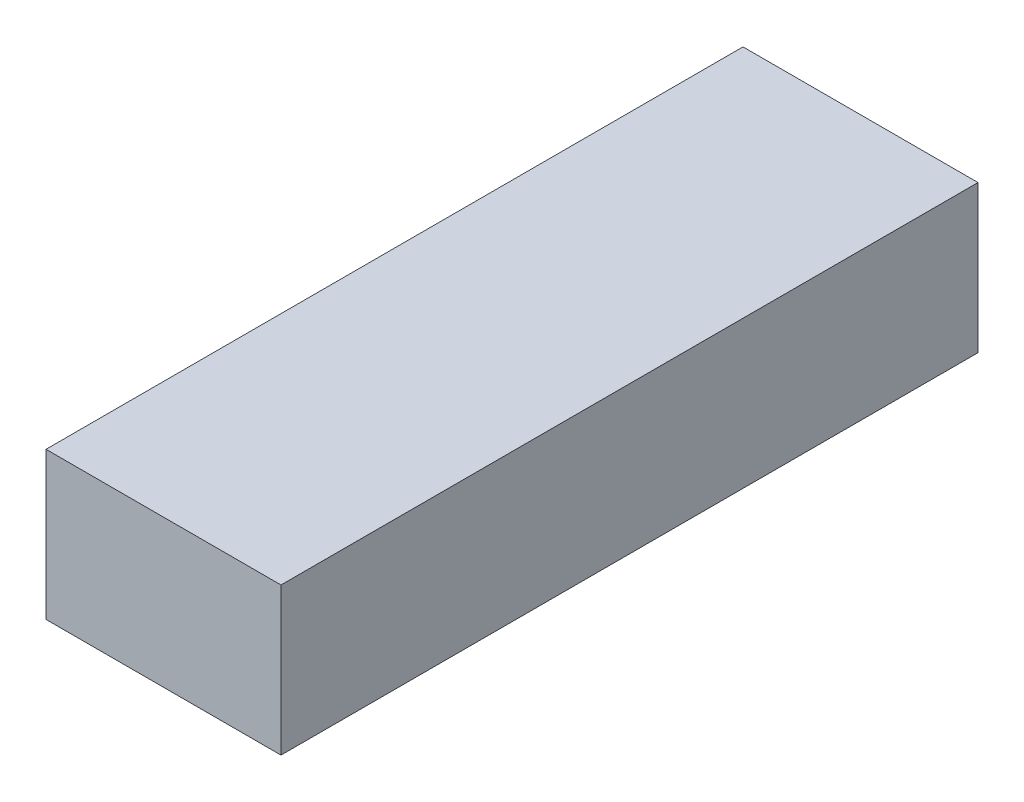
from build123d import *

# Parameters (mm, degrees)
SKETCH1_W           = 11.8
SKETCH1_H           = 35
SKETCH1_W_2         = 7.8
SKETCH1_H_2         = 7.8
BOSS_EXTRUDE1_DEPTH = 2.8
SKETCH2_W           = 11.8
SKETCH2_H           = 35
BOSS_EXTRUDE2_DEPTH = 3
SKETCH3_W           = 11.8
SKETCH3_H           = 35
BOSS_EXTRUDE3_DEPTH = 1.6
CUT_EXTRUDE1_REACH  = 15.365
SKETCH4_R           = 4.125


with BuildPart() as part:
    # Sketch1 → Boss-Extrude1 (new body)
    with BuildSketch(Plane(origin=(0, 0, 0), x_dir=(1, 0, 0), z_dir=(0, 1, 0))):
        with Locations((0, 9.2)):
            Rectangle(SKETCH1_W, SKETCH1_H)
        Rectangle(SKETCH1_W_2, SKETCH1_H_2, mode=Mode.SUBTRACT)
    extrude(amount=BOSS_EXTRUDE1_DEPTH)

    # Sketch2 → Boss-Extrude2 (add)
    with BuildSketch(Plane(origin=(0, 2.8, 0), x_dir=(1, 0, 0), z_dir=(0, 1, 0))):
        with Locations((0, 9.2)):
            Rectangle(SKETCH2_W, SKETCH2_H)
        Polygon((-3.9, 3.9), (-3.4, 3.9), (-3.4, 24.7), (3.4, 24.7), (3.4, 3.9), (3.9, 3.9), (3.9, -3.9), (-3.9, -3.9), align=None, mode=Mode.SUBTRACT)
        Polygon((3.4, -3.4), (-3.4, -3.4), (-3.4, 3.4), (-3.4, 3.9), (-3.9, 3.9), (-3.9, -3.9), (3.9, -3.9), (3.9, 3.9), (3.4, 3.9), (3.4, 3.4), align=None)
    extrude(amount=BOSS_EXTRUDE2_DEPTH)

    # Sketch3 → Boss-Extrude3 (add)
    with BuildSketch(Plane(origin=(0, 5.8, 0), x_dir=(1, 0, 0), z_dir=(0, 1, 0))):
        with Locations((0, 9.2)):
            Rectangle(SKETCH3_W, SKETCH3_H)
    extrude(amount=BOSS_EXTRUDE3_DEPTH)

    # Cut-Extrude1: up to this face of the body (flat: up to its plane)
    cut_extrude1_end = Plane(part.part.faces().sort_by_distance((0, 5.8, -10.65))[0])
    # Sketch4 → Cut-Extrude1 (cut, up to the picked face)
    with BuildSketch(Plane(origin=(0, -4.565968913, -0.805103513), x_dir=(-1, 0, 0), z_dir=(0, -0.984807753, -0.173648178)), mode=Mode.PRIVATE) as cut_extrude1_sk1:
        with Locations((0, 20.169367005)):
            Circle(SKETCH4_R)
    cut_extrude1_tool1 = split(extrude(cut_extrude1_sk1.sketch, amount=-CUT_EXTRUDE1_REACH, mode=Mode.PRIVATE), bisect_by=cut_extrude1_end, keep=Keep.BOTH, mode=Mode.PRIVATE)
    add(cut_extrude1_tool1.solids().sort_by_distance((0, -1.063595, -20.668053))[0], mode=Mode.SUBTRACT)


solid = part.part
